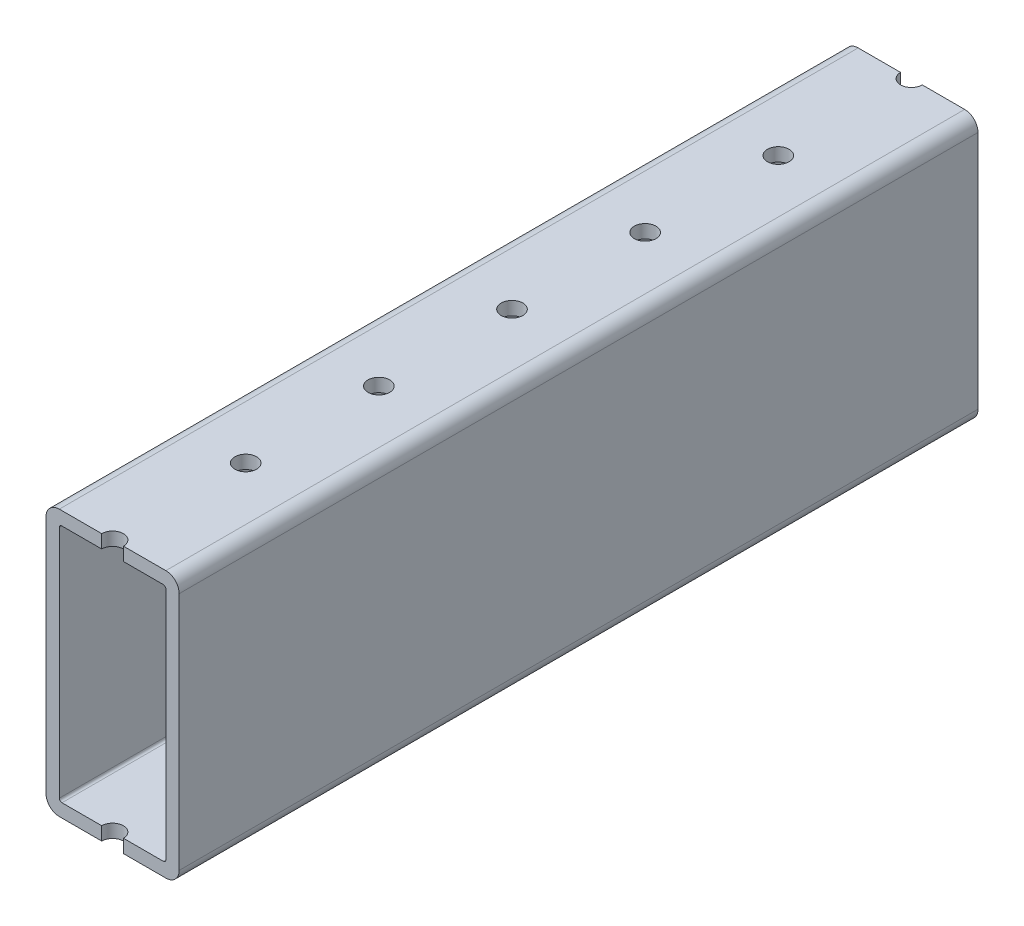
from build123d import *

# Parameters (mm, degrees)
SKETCH1_W                 = 152.4
SKETCH1_H                 = 50.8
BOSS_EXTRUDE1_DEPTH       = 25.4
SKETCH2_W                 = 20.32
SKETCH2_H                 = 45.72
CUT_EXTRUDE1_DEPTH        = 153.4
F_6_CLEARANCE_HOLE1_D     = 4.1402
F_6_CLEARANCE_HOLE1_DEPTH = 50.8
F_6_CLEARANCE_HOLE2_D     = 4.1402
F_6_CLEARANCE_HOLE2_DEPTH = 50.8
FILLET1_R                 = 0.5
FILLET2_R                 = 2.54


with BuildPart() as part:
    # Sketch1 → Boss-Extrude1 (new body)
    with BuildSketch(Plane(origin=(12.7, 0, 0), x_dir=(0, 0, -1), z_dir=(1, 0, 0))):
        Rectangle(SKETCH1_W, SKETCH1_H)
    extrude(amount=-BOSS_EXTRUDE1_DEPTH)

    # Sketch2 → Cut-Extrude1 (cut, through all)
    with BuildSketch(Plane(origin=(0, 0, -76.2), x_dir=(-1, 0, 0), z_dir=(0, 0, -1))):
        Rectangle(SKETCH2_W, SKETCH2_H)
    extrude(amount=-CUT_EXTRUDE1_DEPTH, mode=Mode.SUBTRACT)

    # #6 Clearance Hole1
    with Locations(Plane(origin=(0, -25.4, 0), x_dir=(-1, 0, 0), z_dir=(0, -1, 0))):
        with Locations((0, 711.2), (0, 736.6), (0, 685.8), (0, 660.4), (0, 635), (0, 609.6), (0, 584.2), (0, 558.8), (0, 533.4), (0, 508), (0, 482.6), (0, 457.2), (0, 431.8), (0, 406.4), (0, 381), (0, 355.6), (0, 330.2), (0, 304.8), (0, 279.4), (0, 254), (0, 228.6), (0, 203.2), (0, 177.8), (0, 152.4), (0, 127), (0, 101.6), (0, 76.2), (0, 50.8), (0, 25.4), (0, 0), (0, -25.4), (0, -50.8), (0, -76.2), (0, -101.6), (0, -127), (0, -152.4), (0, -177.8), (0, -203.2), (0, -228.6), (0, -254), (0, -279.4), (0, -304.8), (0, -330.2), (0, -355.6), (0, -381), (0, -406.4), (0, -431.8), (0, -457.2), (0, -482.6), (0, -508), (0, -533.4), (0, -558.8), (0, -584.2), (0, -609.6), (0, -635), (0, -660.4), (0, -685.8), (0, -711.2), (0, -736.6)):
            Hole(F_6_CLEARANCE_HOLE1_D / 2, depth=F_6_CLEARANCE_HOLE1_DEPTH)

    # #6 Clearance Hole2
    with Locations(Plane(origin=(0, 25.4, 0), x_dir=(1, 0, 0), z_dir=(0, 1, 0))):
        with Locations((0, 711.2), (0, 736.6), (0, 685.8), (0, 660.4), (0, 635), (0, 609.6), (0, 584.2), (0, 558.8), (0, 533.4), (0, 508), (0, 482.6), (0, 457.2), (0, 431.8), (0, 406.4), (0, 381), (0, 355.6), (0, 330.2), (0, 304.8), (0, 279.4), (0, 254), (0, 228.6), (0, 203.2), (0, 177.8), (0, 152.4), (0, 127), (0, 101.6), (0, 76.2), (0, 50.8), (0, 25.4), (0, 0), (0, -25.4), (0, -50.8), (0, -76.2), (0, -101.6), (0, -127), (0, -152.4), (0, -177.8), (0, -203.2), (0, -228.6), (0, -254), (0, -279.4), (0, -304.8), (0, -330.2), (0, -355.6), (0, -381), (0, -406.4), (0, -431.8), (0, -457.2), (0, -482.6), (0, -508), (0, -533.4), (0, -558.8), (0, -584.2), (0, -609.6), (0, -635), (0, -660.4), (0, -685.8), (0, -711.2), (0, -736.6)):
            Hole(F_6_CLEARANCE_HOLE2_D / 2, depth=F_6_CLEARANCE_HOLE2_DEPTH)

    # Fillet1
    fillet1_edges = [part.edges().sort_by_distance(p)[0] for p in [
        (-10.16, -22.86, 0),
        (10.16, -22.86, 0),
        (10.16, 22.86, 0),
        (-10.16, 22.86, 0),
    ]]
    fillet(fillet1_edges, radius=FILLET1_R)

    # Fillet2
    fillet2_edges = [part.edges().sort_by_distance(p)[0] for p in [
        (-12.7, 25.4, 0),
        (-12.7, -25.4, 0),
        (12.7, 25.4, 0),
        (12.7, -25.4, 0),
    ]]
    fillet(fillet2_edges, radius=FILLET2_R)


solid = part.part
